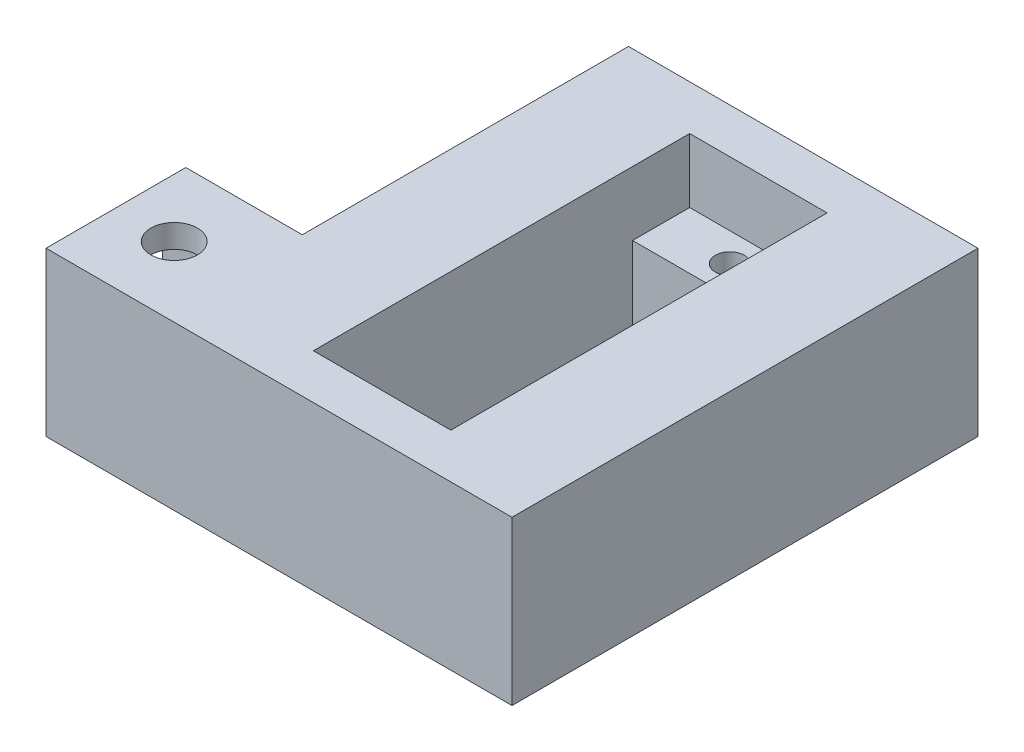
from build123d import *

# Parameters (mm, degrees)
BOSS_EXTRUDE1_DEPTH = 40
SKETCH4_W           = 11.8
SKETCH4_H           = 32.3
CUT_EXTRUDE1_DEPTH  = 5.5
SKETCH5_W           = 11.8
SKETCH5_H           = 22.5
CUT_EXTRUDE2_DEPTH  = 9.498848241
SKETCH6_R           = 1.25
CUT_EXTRUDE3_DEPTH  = 9.498848241
SKETCH7_W           = 12
SKETCH7_H           = 13.998848241
BOSS_EXTRUDE3_DEPTH = 10
SKETCH11_W          = 8
SKETCH11_H          = 9.998848241
CUT_EXTRUDE5_DEPTH  = 10
SKETCH12_R          = 2
CUT_EXTRUDE6_DEPTH  = 14.998848241


with BuildPart() as part:
    # Sketch1 → Boss-Extrude1 (new body)
    with BuildSketch(Plane.XY):
        Polygon((8.670952565, 9.003587153), (-11.329047435, 9.003587153), (-21.329047435, 9.003587153), (-21.329047435, -4.995261088), (-11.329047435, -4.995261088), (8.670952565, -4.995261088), align=None)
    extrude(amount=BOSS_EXTRUDE1_DEPTH)

    # Sketch4 → Cut-Extrude1 (cut)
    with BuildSketch(Plane(origin=(0, 9.003587153, 0), x_dir=(1, 0, 0), z_dir=(0, 1, 0))):
        with Locations((-6.329047435, -20)):
            Rectangle(SKETCH4_W, SKETCH4_H)
    extrude(amount=-CUT_EXTRUDE1_DEPTH, mode=Mode.SUBTRACT)

    # Sketch5 → Cut-Extrude2 (cut, through all)
    with BuildSketch(Plane(origin=(0, 3.503587153, 0), x_dir=(1, 0, 0), z_dir=(0, 1, 0))):
        with Locations((-6.329047435, -20)):
            Rectangle(SKETCH5_W, SKETCH5_H)
    extrude(amount=-CUT_EXTRUDE2_DEPTH, mode=Mode.SUBTRACT)

    # Sketch6 → Cut-Extrude3 (cut, through all)
    with BuildSketch(Plane(origin=(0, 3.503587153, 0), x_dir=(1, 0, 0), z_dir=(0, 1, 0))):
        with Locations((-6.329047435, -6.3)):
            Circle(SKETCH6_R)
        with Locations((-6.329047435, -33.7)):
            Circle(SKETCH6_R)
    extrude(amount=-CUT_EXTRUDE3_DEPTH, mode=Mode.SUBTRACT)

    # Sketch7 → Boss-Extrude3 (add)
    with BuildSketch(Plane.ZY.offset(21.329047435)):
        with Locations((34, 2.004163032)):
            Rectangle(SKETCH7_W, SKETCH7_H)
    extrude(amount=BOSS_EXTRUDE3_DEPTH)

    # Sketch11 → Cut-Extrude5 (cut)
    with BuildSketch(Plane.ZY.offset(31.329047435)):
        with Locations((34, 2.004163033)):
            Rectangle(SKETCH11_W, SKETCH11_H)
    extrude(amount=-CUT_EXTRUDE5_DEPTH, mode=Mode.SUBTRACT)

    # Sketch12 → Cut-Extrude6 (cut, through all)
    with BuildSketch(Plane(origin=(0, 9.003587153, 0), x_dir=(1, 0, 0), z_dir=(0, 1, 0))):
        with Locations((-26.329047435, -34)):
            Circle(SKETCH12_R)
    extrude(amount=-CUT_EXTRUDE6_DEPTH, mode=Mode.SUBTRACT)


solid = part.part
